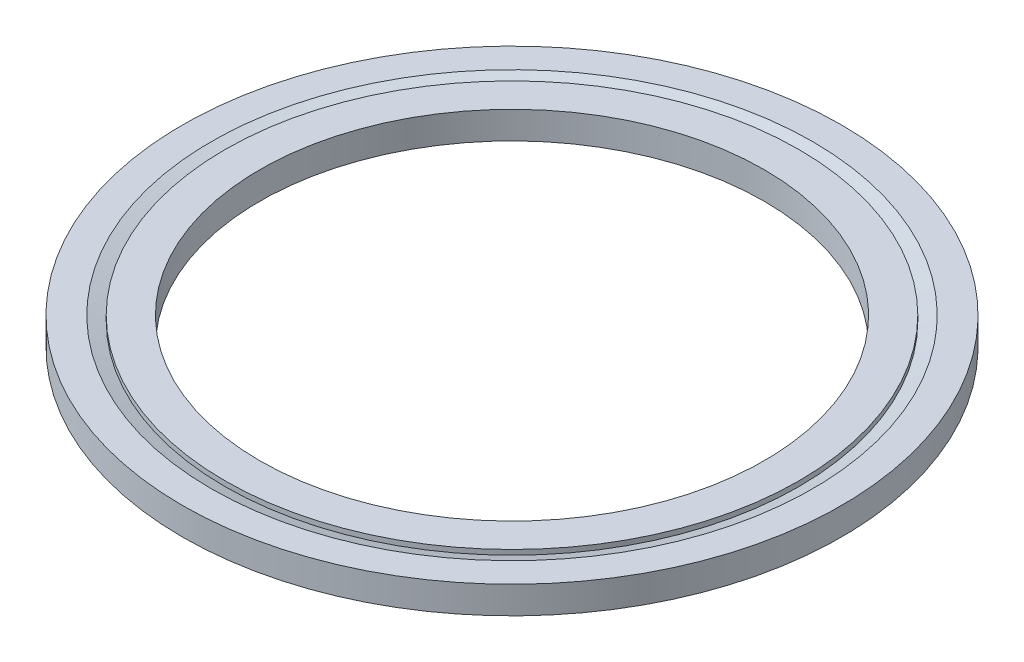
from build123d import *

# Parameters (mm, degrees)
SKETCH1_W          = 24.0665
SKETCH1_H          = 1.999996
SKETCH3_R          = 18.415
CUT_EXTRUDE1_DEPTH = 2.999996


with BuildPart() as part:
    # Sketch1 → Revolve1 (revolve)
    with BuildSketch(Plane.XY):
        with Locations((12.03325, 0)):
            Rectangle(SKETCH1_W, SKETCH1_H)
    revolve(axis=Axis((0, 0.999998, 0), (0, -1, 0)))

    # Sketch2 → Cut-Revolve1 (revolve, cut)
    with BuildSketch(Plane.XY):
        Polygon((-20.955, 0.635), (-20.955, 1.799850338), (-24.1554, 1.799850338), align=None)
        Polygon((-24.1554, -1.799850338), (-20.955, -0.635), (-20.955, -1.799850338), align=None)
    revolve(axis=Axis((0, 0, 0), (0, 1, 0)), mode=Mode.SUBTRACT)

    # Sketch3 → Cut-Extrude1 (cut, through all)
    with BuildSketch(Plane(origin=(0, 0.999998, 0), x_dir=(1, 0, 0), z_dir=(0, 1, 0))):
        Circle(SKETCH3_R)
    extrude(amount=-CUT_EXTRUDE1_DEPTH, mode=Mode.SUBTRACT)


solid = part.part
